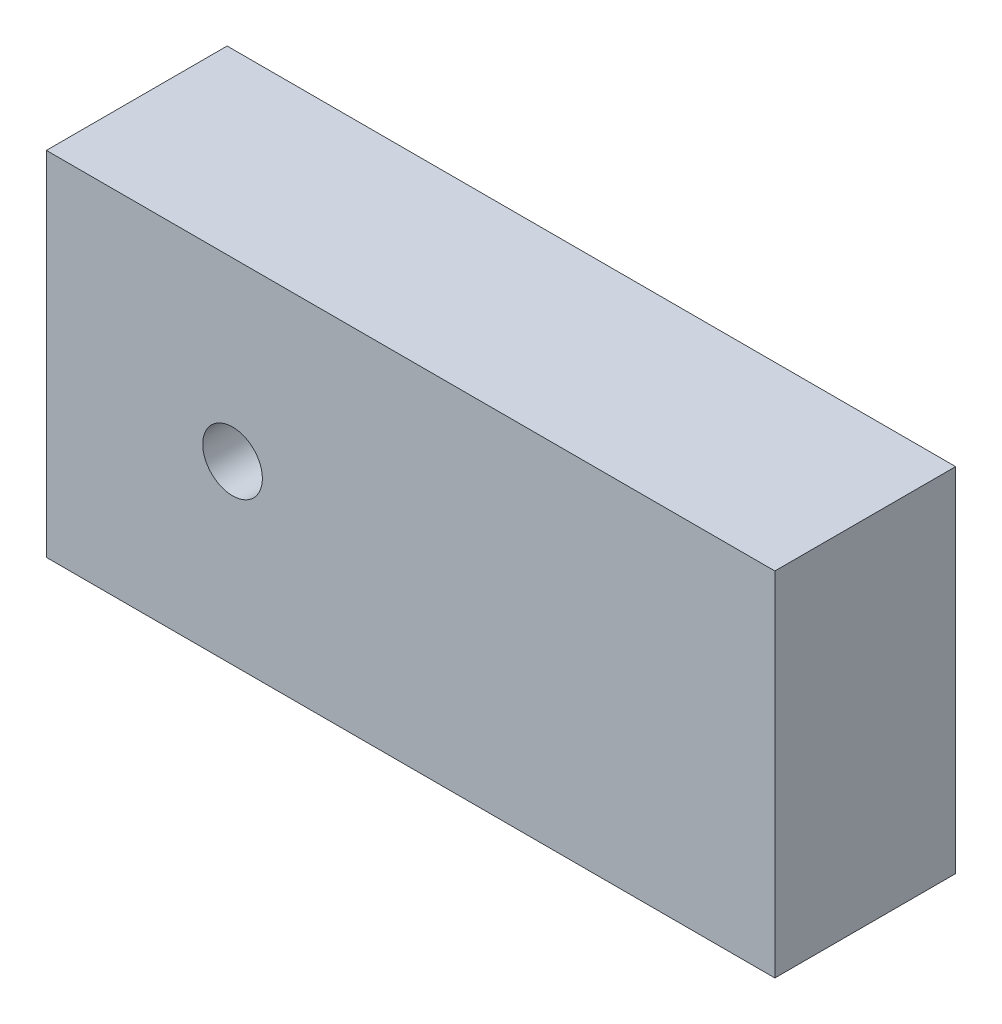
from build123d import *

# Parameters (mm, degrees)
SKETCH_1_W      = 40.3
SKETCH_1_H      = 19.5
SKETCH_1_R      = 1.65
EXTRUDE_1_DEPTH = 10


with BuildPart() as part:
    # 草图1 → 凸台-拉伸1 (new body)
    with BuildSketch(Plane.XY):
        Rectangle(SKETCH_1_W, SKETCH_1_H)
        with Locations((-9.85, 0)):
            Circle(SKETCH_1_R, mode=Mode.SUBTRACT)
    extrude(amount=EXTRUDE_1_DEPTH)


solid = part.part
